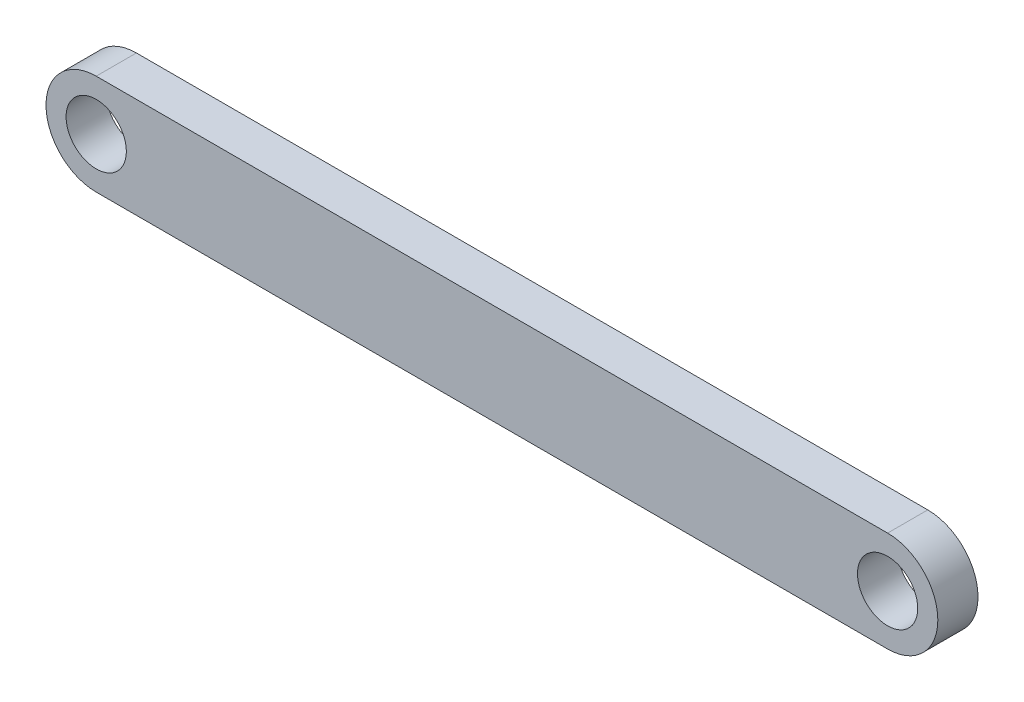
from build123d import *

# Parameters (mm, degrees)
SKETCH1_R           = 1.5
BOSS_EXTRUDE1_DEPTH = 2


with BuildPart() as part:
    # Sketch1 → Boss-Extrude1 (new body)
    with BuildSketch(Plane.XY):
        with BuildLine():
            Line((-0.063405544, 1.16361841), (39.336594456, 1.16361841))
            ThreePointArc((39.336594456, 1.16361841), (41.836594456, -1.33638159), (39.336594456, -3.83638159))
            Line((39.336594456, -3.83638159), (-0.063405544, -3.83638159))
            ThreePointArc((-0.063405544, -3.83638159), (-2.563405544, -1.33638159), (-0.063405544, 1.16361841))
        make_face()
        with Locations((-0.063405544, -1.33638159)):
            Circle(SKETCH1_R, mode=Mode.SUBTRACT)
        with Locations((39.336594456, -1.33638159)):
            Circle(SKETCH1_R, mode=Mode.SUBTRACT)
    extrude(amount=BOSS_EXTRUDE1_DEPTH)


solid = part.part
